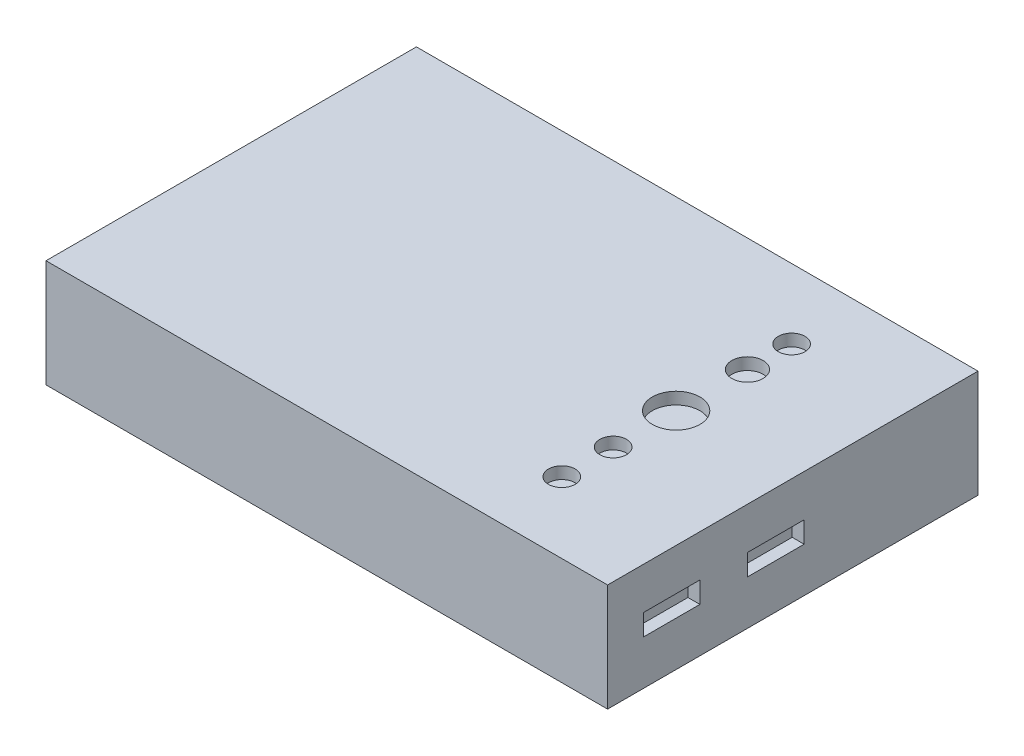
from build123d import *

# Parameters (mm, degrees)
SKETCH1_W           = 119.38
SKETCH1_H           = 78.74
BOSS_EXTRUDE1_DEPTH = 22.86
SKETCH2_W           = 12
SKETCH2_H           = 4.5
CUT_EXTRUDE1_DEPTH  = 2.54
SKETCH3_R           = 5.06527112
SKETCH3_R_2         = 3.320502589
SKETCH3_R_3         = 2.836896815
CUT_EXTRUDE2_DEPTH  = 2.54


with BuildPart() as part:
    # Sketch1 → Boss-Extrude1 (new body)
    with BuildSketch(Plane(origin=(0, 0, 0), x_dir=(1, 0, 0), z_dir=(0, 1, 0))):
        with Locations((59.69, 39.37)):
            Rectangle(SKETCH1_W, SKETCH1_H)
    extrude(amount=BOSS_EXTRUDE1_DEPTH)

    # Sketch2 → Cut-Extrude1 (cut)
    with BuildSketch(Plane(origin=(119.38, 0, 0), x_dir=(0, 0, -1), z_dir=(1, 0, 0))):
        with Locations((35.78, 11.72)):
            Rectangle(SKETCH2_W, SKETCH2_H)
        with Locations((13.62, 11.72)):
            Rectangle(SKETCH2_W, SKETCH2_H)
    extrude(amount=-CUT_EXTRUDE1_DEPTH, mode=Mode.SUBTRACT)

    # Sketch3 → Cut-Extrude2 (cut)
    with BuildSketch(Plane(origin=(0, 22.86, 0), x_dir=(1, 0, 0), z_dir=(0, 1, 0))):
        with Locations((94.579217674, 39.37)):
            Circle(SKETCH3_R)
        with Locations((94.579217674, 54.530950953)):
            Circle(SKETCH3_R_2)
        with Locations((94.579217674, 63.919322254)):
            Circle(SKETCH3_R_3)
        with Locations((94.579217674, 25.985227401)):
            Circle(SKETCH3_R_3)
        with Locations((94.579217674, 15.074417511)):
            Circle(SKETCH3_R_3)
    extrude(amount=-CUT_EXTRUDE2_DEPTH, mode=Mode.SUBTRACT)


solid = part.part
